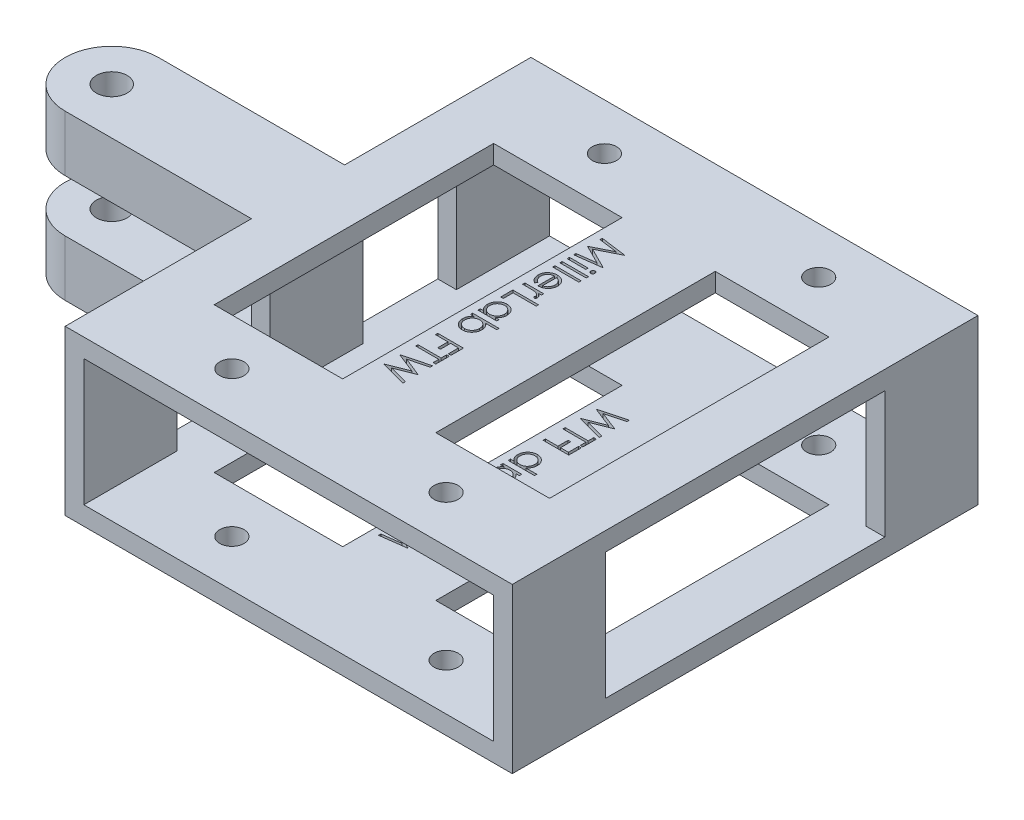
from build123d import *

# Parameters (mm, degrees)
SKETCH1_W             = 60.96
SKETCH1_H             = 22.352
SKETCH1_W_2           = 55.88
SKETCH1_H_2           = 17.272
BOSS_EXTRUDE1_DEPTH   = 12.7
SKETCH2_W             = 7.62
SKETCH2_H             = 2.54
SKETCH2_W_2           = 12.7
BOSS_EXTRUDE2_DEPTH   = 38.1
SKETCH4_W             = 60.96
SKETCH4_H             = 22.352
SKETCH4_W_2           = 55.88
SKETCH4_H_2           = 17.272
BOSS_EXTRUDE3_DEPTH   = 12.7
SKETCH6_W             = 12.7
SKETCH6_H             = 22.352
BOSS_EXTRUDE4_DEPTH   = 2.54
SKETCH7_W             = 12.7
SKETCH7_H             = 5.08
BOSS_EXTRUDE5_DEPTH   = 25.4
SKETCH8_W             = 6.35
SKETCH8_H             = 5.08
REVOLVE2_ANGLE        = 180
SKETCH10_R            = 2.0955
CUT_EXTRUDE4_DEPTH    = 20.812
SKETCH11_W            = 2.557692308
SKETCH11_H            = 0.314102564
SKETCH11_W_2          = 3.58974359
CUT_EXTRUDE7_DEPTH    = 2.54
SKETCH14_W            = 2.557692308
SKETCH14_H            = 0.314102564
SKETCH14_W_2          = 3.58974359
CUT_EXTRUDE8_DEPTH    = 2.54
M4X0_7_TAPPED_HOLE1_D = 3.3
SKETCH17_R            = 2.0955
BOSS_EXTRUDE6_DEPTH   = 2.54
SKETCH18_R            = 2.0955
BOSS_EXTRUDE7_DEPTH   = 2.54


with BuildPart() as part:
    # Sketch1 → Boss-Extrude1 (new body)
    with BuildSketch(Plane.XY):
        Rectangle(SKETCH1_W, SKETCH1_H)
        Rectangle(SKETCH1_W_2, SKETCH1_H_2, mode=Mode.SUBTRACT)
    extrude(amount=-BOSS_EXTRUDE1_DEPTH)

    # Sketch2 → Boss-Extrude2 (add)
    with BuildSketch(Plane(origin=(0, 0, -12.7), x_dir=(-1, 0, 0), z_dir=(0, 0, -1))):
        with Locations((-26.67, 9.906)):
            Rectangle(SKETCH2_W, SKETCH2_H)
        with Locations((-1.00660043, 9.906)):
            Rectangle(SKETCH2_W_2, SKETCH2_H)
        with Locations((26.67, 9.906)):
            Rectangle(SKETCH2_W, SKETCH2_H)
        with Locations((26.67, -9.906)):
            Rectangle(SKETCH2_W, SKETCH2_H)
        with Locations((-1.00660043, -9.906)):
            Rectangle(SKETCH2_W_2, SKETCH2_H)
        with Locations((-26.67, -9.906)):
            Rectangle(SKETCH2_W, SKETCH2_H)
    extrude(amount=BOSS_EXTRUDE2_DEPTH)

    # Sketch4 → Boss-Extrude3 (add)
    with BuildSketch(Plane(origin=(0, 0, -50.8), x_dir=(-1, 0, 0), z_dir=(0, 0, -1))):
        Rectangle(SKETCH4_W, SKETCH4_H)
        Rectangle(SKETCH4_W_2, SKETCH4_H_2, mode=Mode.SUBTRACT)
    extrude(amount=BOSS_EXTRUDE3_DEPTH)

    # Sketch6 → Boss-Extrude4 (add)
    with BuildSketch(Plane.ZY.offset(30.48)):
        with Locations((-31.75, 0)):
            Rectangle(SKETCH6_W, SKETCH6_H)
    extrude(amount=-BOSS_EXTRUDE4_DEPTH)

    # Sketch7 → Boss-Extrude5 (add)
    with BuildSketch(Plane.ZY.offset(30.48)):
        with Locations((-31.75, 6.096)):
            Rectangle(SKETCH7_W, SKETCH7_H)
        with Locations((-31.75, -6.096)):
            Rectangle(SKETCH7_W, SKETCH7_H)
    extrude(amount=BOSS_EXTRUDE5_DEPTH)

    # Sketch8 → Revolve2 (revolve)
    with BuildSketch(Plane.ZY.offset(55.88)):
        with Locations((-28.575, 6.096)):
            Rectangle(SKETCH8_W, SKETCH8_H)
        with Locations((-28.575, -6.096)):
            Rectangle(SKETCH8_W, SKETCH8_H)
    revolve(axis=Axis((-55.88, 8.636, -31.75), (0, -1, 0)), revolution_arc=REVOLVE2_ANGLE)

    # Sketch10 → Cut-Extrude4 (cut, through all)
    with BuildSketch(Plane(origin=(0, 8.636, 0), x_dir=(1, 0, 0), z_dir=(0, 1, 0))):
        with Locations((-55.88, 31.75)):
            Circle(SKETCH10_R)
    extrude(amount=-CUT_EXTRUDE4_DEPTH, mode=Mode.SUBTRACT)

    # Sketch11 → Cut-Extrude7 (cut)
    with BuildSketch(Plane(origin=(0, -11.176, 0), x_dir=(-1, 0, 0), z_dir=(0, -1, 0))):
        Polygon((4.247617225, 16.493589744), (0.747617225, 16.955629006), (0.747617225, 17.000500801), (3.619412097, 18.445512821), (0.747617225, 19.887019231), (0.747617225, 19.932592147), (4.247617225, 20.397435897), (4.247617225, 20.08193109), (1.729187738, 19.746794872), (4.247617225, 18.483373397), (4.247617225, 18.412560096), (1.723578763, 17.144230769), (4.247617225, 16.809795673), align=None)
        with BuildLine():
            add(Edge.make_bspline(
                [(0.61300184, 21.136418269), (0.613905993, 21.155909585), (0.615676497, 21.194077325), (0.630837974, 21.249270593), (0.656537659, 21.299527605), (0.69101734, 21.344105338), (0.731566784, 21.382357224), (0.778827752, 21.409137935), (0.829886391, 21.426350331), (0.86550148, 21.428428886), (0.883634853, 21.429487179)],
                knots=[0, 0, 0, 0, 5.84e-05, 0.000114358, 0.000170171, 0.000226684, 0.000282761, 0.000336156, 0.000388483, 0.00044276, 0.00044276, 0.00044276, 0.00044276], degree=3))
            add(Edge.make_bspline(
                [(0.883634853, 21.429487179), (0.901297506, 21.42840502), (0.936214481, 21.426265718), (0.986387953, 21.40915123), (1.032992237, 21.382128992), (1.073462947, 21.344129866), (1.107923567, 21.299521105), (1.133628306, 21.249272319), (1.148788443, 21.194076871), (1.150559132, 21.155909431), (1.151463379, 21.136418269)],
                knots=[0, 0, 0, 0, 5.2882e-05, 0.000104542, 0.000157332, 0.000213408, 0.000269922, 0.000325735, 0.000381693, 0.000440092, 0.000440092, 0.000440092, 0.000440092], degree=3))
            add(Edge.make_bspline(
                [(1.151463379, 21.136418269), (1.150593659, 21.117149994), (1.148900862, 21.079646814), (1.133330844, 21.025279972), (1.107914771, 20.975451482), (1.073688586, 20.93078681), (1.032743689, 20.893556616), (0.986416395, 20.866458291), (0.93620724, 20.849383329), (0.901295074, 20.8472387), (0.883634853, 20.846153846)],
                knots=[0, 0, 0, 0, 5.7701e-05, 0.000112308, 0.000168121, 0.000224634, 0.000280239, 0.000333029, 0.000384689, 0.000437571, 0.000437571, 0.000437571, 0.000437571], degree=3))
            add(Edge.make_bspline(
                [(0.883634853, 20.846153846), (0.865504004, 20.847214933), (0.829893871, 20.849298974), (0.778798838, 20.86647109), (0.731817336, 20.893330898), (0.690791837, 20.930811461), (0.656546402, 20.975444922), (0.631135421, 21.025281667), (0.615564081, 21.079646366), (0.613871467, 21.117149842), (0.61300184, 21.136418269)],
                knots=[0, 0, 0, 0, 5.4277e-05, 0.000106603, 0.000159999, 0.000215605, 0.000272118, 0.000327931, 0.000382538, 0.000440239, 0.000440239, 0.000440239, 0.000440239], degree=3))
        make_face()
        with Locations((2.968771071, 21.137820513)):
            Rectangle(SKETCH11_W, SKETCH11_H)
        with Locations((2.45274543, 22.125)):
            Rectangle(SKETCH11_W_2, SKETCH11_H)
        with Locations((2.45274543, 23.112179487)):
            Rectangle(SKETCH11_W_2, SKETCH11_H)
        with BuildLine():
            Line((3.439924917, 26.086338141), (3.586459372, 26.365384615))
            add(Edge.make_bspline(
                [(3.586459372, 26.365384615), (3.625893354, 26.343136354), (3.702616265, 26.299850049), (3.808030234, 26.225713126), (3.902297768, 26.147284659), (3.983909375, 26.062178381), (4.055982557, 25.972958905), (4.118149707, 25.877931674), (4.171532545, 25.777872338), (4.215274799, 25.671678794), (4.249663078, 25.559478251), (4.275059057, 25.440619641), (4.289786311, 25.314541759), (4.291573757, 25.228203797), (4.29248902, 25.183994391)],
                knots=[0, 0, 0, 0, 0.000135759, 0.000264133, 0.000386042, 0.00050306, 0.000617265, 0.000729664, 0.000843204, 0.000957002, 0.001073654, 0.001194802, 0.001321164, 0.001453767, 0.001453767, 0.001453767, 0.001453767], degree=3))
            add(Edge.make_bspline(
                [(4.29248902, 25.183994391), (4.291341844, 25.134852414), (4.289104038, 25.038990652), (4.269811574, 24.899450904), (4.238339213, 24.76807149), (4.194373678, 24.644859772), (4.136946332, 24.530117572), (4.06698693, 24.423616521), (3.984854375, 24.324797737), (3.889839071, 24.236770712), (3.788152887, 24.157537276), (3.682212278, 24.087573696), (3.572384128, 24.029353967), (3.459321889, 23.981271988), (3.343282485, 23.943344417), (3.223601343, 23.916392501), (3.100753036, 23.900999352), (3.017657427, 23.898629938), (2.975782289, 23.897435897)],
                knots=[0, 0, 0, 0, 0.000147371, 0.000287478, 0.000421649, 0.000552053, 0.000679042, 0.000805636, 0.000933558, 0.00106351, 0.001193382, 0.001319977, 0.001443869, 0.00156576, 0.001688149, 0.001809597, 0.001933259, 0.002058885, 0.002058885, 0.002058885, 0.002058885], degree=3))
            add(Edge.make_bspline(
                [(2.975782289, 23.897435897), (2.936487459, 23.898495039), (2.858610294, 23.900594117), (2.743344749, 23.913824904), (2.631316297, 23.937273197), (2.522431849, 23.969449521), (2.416873715, 24.011000768), (2.314577651, 24.061832987), (2.215652511, 24.122025365), (2.153249378, 24.168498038), (2.121815943, 24.191907051)],
                knots=[0, 0, 0, 0, 0.000117891, 0.000233644, 0.000347498, 0.000460856, 0.000573868, 0.000687374, 0.000803169, 0.000920699, 0.000920699, 0.000920699, 0.000920699], degree=3))
            add(Edge.make_bspline(
                [(2.121815943, 24.191907051), (2.083884284, 24.223560071), (2.009344387, 24.285761747), (1.912294563, 24.392058508), (1.829276736, 24.505608288), (1.761550628, 24.627553262), (1.709458542, 24.757688021), (1.672406131, 24.895341339), (1.649350429, 25.040893688), (1.646507336, 25.140671415), (1.645053122, 25.191706731)],
                knots=[0, 0, 0, 0, 0.000148071, 0.000290976, 0.000430515, 0.000569233, 0.000708282, 0.00084996, 0.000996123, 0.001149162, 0.001149162, 0.001149162, 0.001149162], degree=3))
            add(Edge.make_bspline(
                [(1.645053122, 25.191706731), (1.64640039, 25.244157352), (1.649043421, 25.347053514), (1.673765573, 25.497043025), (1.712494308, 25.639244931), (1.768920238, 25.772485713), (1.838864031, 25.898818414), (1.927269712, 26.015335502), (2.029596658, 26.125235447), (2.108372465, 26.189137332), (2.148458571, 26.221654647)],
                knots=[0, 0, 0, 0, 0.000157241, 0.00030847, 0.000454763, 0.000598385, 0.000741531, 0.000886803, 0.001036096, 0.001190777, 0.001190777, 0.001190777, 0.001190777], degree=3))
            add(Edge.make_bspline(
                [(2.148458571, 26.221654647), (2.178662153, 26.243781586), (2.238868271, 26.287888179), (2.337039428, 26.343135279), (2.439750023, 26.391092674), (2.54866032, 26.429425635), (2.6624799, 26.460465136), (2.782022445, 26.482921955), (2.907252356, 26.496091573), (2.992578911, 26.498680271), (3.036078763, 26.5)],
                knots=[0, 0, 0, 0, 0.000112234, 0.000223721, 0.000337279, 0.000451932, 0.000569628, 0.000690912, 0.000816421, 0.00094695, 0.00094695, 0.00094695, 0.00094695], degree=3))
            Line((3.036078763, 26.5), (3.036078763, 24.211538462))
            add(Edge.make_bspline(
                [(3.036078763, 24.211538462), (3.069779228, 24.213078068), (3.136049831, 24.216105642), (3.233020615, 24.230220785), (3.325393957, 24.252469559), (3.412476999, 24.283738621), (3.495407126, 24.321605467), (3.573569163, 24.367991184), (3.646607093, 24.423330737), (3.715174231, 24.485056437), (3.776234992, 24.553763532), (3.830886768, 24.626046279), (3.876692365, 24.702939844), (3.913872255, 24.783837928), (3.942978571, 24.868609713), (3.962846391, 24.957281908), (3.976153498, 25.049680025), (3.977633163, 25.112665759), (3.978386456, 25.144731571)],
                knots=[0, 0, 0, 0, 0.000101159, 0.000198924, 0.000293472, 0.000385722, 0.000476069, 0.000566611, 0.000657757, 0.000750573, 0.000842919, 0.000933083, 0.001022062, 0.001110842, 0.001199752, 0.001290403, 0.001383113, 0.001479259, 0.001479259, 0.001479259, 0.001479259], degree=3))
            add(Edge.make_bspline(
                [(3.978386456, 25.144731571), (3.977783296, 25.176084086), (3.97658651, 25.238293491), (3.96478247, 25.330914198), (3.946074092, 25.422195018), (3.919128337, 25.511229558), (3.887575222, 25.596720251), (3.850437409, 25.676326669), (3.808096098, 25.748996376), (3.759980502, 25.817180712), (3.700930029, 25.882958118), (3.627948805, 25.949242628), (3.540209077, 26.018748352), (3.4746109, 26.062960389), (3.439924917, 26.086338141)],
                knots=[0, 0, 0, 0, 9.4016e-05, 0.000186545, 0.000279636, 0.000373251, 0.000465322, 0.000552831, 0.000636406, 0.000717339, 0.000802755, 0.000900997, 0.001012795, 0.001138241, 0.001138241, 0.001138241, 0.001138241], degree=3))
        make_face()
        with BuildLine():
            add(Edge.make_bspline(
                [(2.721976199, 26.185897436), (2.680292506, 26.174447368), (2.600273356, 26.152466957), (2.489504895, 26.105655852), (2.390493119, 26.054207803), (2.304883383, 25.992274475), (2.228728754, 25.922787657), (2.163242181, 25.841416914), (2.102884461, 25.751691387), (2.052620849, 25.651823925), (2.011316259, 25.545752804), (1.980944618, 25.435658203), (1.963091257, 25.322462266), (1.96047371, 25.246222059), (1.959155687, 25.207832532)],
                knots=[0, 0, 0, 0, 0.000129543, 0.00024868, 0.000360034, 0.000463544, 0.000564759, 0.000668354, 0.000776083, 0.000888652, 0.001002969, 0.001117099, 0.00123064, 0.001345797, 0.001345797, 0.001345797, 0.001345797], degree=3))
            add(Edge.make_bspline(
                [(1.959155687, 25.207832532), (1.959760225, 25.176480698), (1.960955271, 25.114504713), (1.972528457, 25.023238257), (1.99112528, 24.935362925), (2.018469047, 24.851141019), (2.051741006, 24.770013865), (2.092638976, 24.692040085), (2.142085337, 24.618222044), (2.179857154, 24.572085873), (2.19893934, 24.548778045)],
                knots=[0, 0, 0, 0, 9.4016e-05, 0.000185849, 0.000275511, 0.000363095, 0.000451113, 0.0005383, 0.000626778, 0.000717114, 0.000717114, 0.000717114, 0.000717114], degree=3))
            add(Edge.make_bspline(
                [(2.19893934, 24.548778045), (2.214032069, 24.532082147), (2.244576075, 24.498293718), (2.297230043, 24.45319403), (2.354040592, 24.40969064), (2.417487555, 24.371031539), (2.485731038, 24.334291803), (2.559268997, 24.300812377), (2.638411838, 24.270371333), (2.693588551, 24.253282931), (2.721976199, 24.244491186)],
                knots=[0, 0, 0, 0, 6.7454e-05, 0.00013651, 0.000207604, 0.000281922, 0.000359087, 0.000440033, 0.000524147, 0.00061328, 0.00061328, 0.00061328, 0.00061328], degree=3))
            Line((2.721976199, 24.244491186), (2.721976199, 26.185897436))
        make_face(mode=Mode.SUBTRACT)
        with BuildLine():
            Line((1.689924917, 27.038461538), (1.689924917, 27.352564103))
            Line((1.689924917, 27.352564103), (2.066427321, 27.352564103))
            add(Edge.make_bspline(
                [(2.066427321, 27.352564103), (2.031355799, 27.375738024), (1.964281786, 27.420057969), (1.875691167, 27.494067787), (1.801504013, 27.569067361), (1.743135084, 27.647026042), (1.699022427, 27.727179508), (1.668025845, 27.808851864), (1.648803921, 27.892242831), (1.646305063, 27.948418293), (1.645053122, 27.9765625)],
                knots=[0, 0, 0, 0, 0.000126023, 0.000241017, 0.000345635, 0.000441829, 0.000532198, 0.000619182, 0.000703214, 0.000787585, 0.000787585, 0.000787585, 0.000787585], degree=3))
            add(Edge.make_bspline(
                [(1.645053122, 27.9765625), (1.646243649, 27.998388826), (1.648693235, 28.043297912), (1.665904059, 28.111280501), (1.693382082, 28.181323953), (1.719222305, 28.226466341), (1.732693347, 28.25)],
                knots=[0, 0, 0, 0, 6.5445e-05, 0.000134658, 0.00020926, 0.000290509, 0.000290509, 0.000290509, 0.000290509], degree=3))
            Line((1.732693347, 28.25), (2.004728603, 28.077524038))
            add(Edge.make_bspline(
                [(2.004728603, 28.077524038), (1.997988337, 28.062415017), (1.985194022, 28.033735203), (1.970052012, 27.991780637), (1.961136096, 27.9530993), (1.959785378, 27.928455741), (1.959155687, 27.916967147)],
                knots=[0, 0, 0, 0, 4.9621e-05, 9.4191e-05, 0.00013366, 0.000168129, 0.000168129, 0.000168129, 0.000168129], degree=3))
            add(Edge.make_bspline(
                [(1.959155687, 27.916967147), (1.960822567, 27.891753846), (1.96422252, 27.840326021), (1.991333186, 27.765074687), (2.033876004, 27.691399312), (2.082319697, 27.633451078), (2.1288541, 27.588424214), (2.169581964, 27.556042035), (2.215672768, 27.526978548), (2.265345001, 27.498786194), (2.319845293, 27.472593368), (2.379262554, 27.449186231), (2.443106141, 27.427296051), (2.487498075, 27.414968511), (2.510237417, 27.408653846)],
                knots=[0, 0, 0, 0, 7.549e-05, 0.000153978, 0.000237202, 0.000329846, 0.000379433, 0.000431335, 0.000485594, 0.00054273, 0.000602625, 0.000666812, 0.000734214, 0.000805, 0.000805, 0.000805, 0.000805], degree=3))
            add(Edge.make_bspline(
                [(2.510237417, 27.408653846), (2.530513468, 27.403913274), (2.575648591, 27.393360613), (2.651025991, 27.38337422), (2.740024618, 27.373109836), (2.842747862, 27.366100296), (2.959590594, 27.35947885), (3.090048753, 27.35582089), (3.234480907, 27.352680486), (3.335221767, 27.352604135), (3.388041904, 27.352564103)],
                knots=[0, 0, 0, 0, 6.2435e-05, 0.000138983, 0.000227868, 0.000331221, 0.000447778, 0.000578955, 0.000722713, 0.000881168, 0.000881168, 0.000881168, 0.000881168], degree=3))
            Line((3.388041904, 27.352564103), (4.247617225, 27.352564103))
            Line((4.247617225, 27.352564103), (4.247617225, 27.038461538))
            Line((4.247617225, 27.038461538), (1.689924917, 27.038461538))
        make_face()
        Polygon((0.747617225, 28.698717949), (0.747617225, 29.012820513), (3.888642866, 29.012820513), (3.888642866, 30.358974359), (4.247617225, 30.358974359), (4.247617225, 28.698717949), align=None)
        with BuildLine():
            Line((1.689924917, 33.455128205), (4.247617225, 33.455128205))
            Line((4.247617225, 33.455128205), (4.247617225, 33.141025641))
            Line((4.247617225, 33.141025641), (3.805209372, 33.141025641))
            add(Edge.make_bspline(
                [(3.805209372, 33.141025641), (3.845182992, 33.105551556), (3.923308021, 33.036220483), (4.026308805, 32.921515667), (4.109711173, 32.798417096), (4.178049309, 32.670013674), (4.229175191, 32.535047659), (4.265579222, 32.394224474), (4.288968191, 32.247409579), (4.291304881, 32.147157707), (4.29248902, 32.096354167)],
                knots=[0, 0, 0, 0, 0.000160263, 0.00031322, 0.000461017, 0.000605284, 0.000748646, 0.000892854, 0.001041096, 0.001193401, 0.001193401, 0.001193401, 0.001193401], degree=3))
            add(Edge.make_bspline(
                [(4.29248902, 32.096354167), (4.291262648, 32.051186213), (4.288844187, 31.962113008), (4.270081884, 31.831083931), (4.239951262, 31.704991681), (4.198050372, 31.583717109), (4.142469551, 31.468044963), (4.075928303, 31.356984867), (3.996687473, 31.251112175), (3.906099444, 31.152040636), (3.807704457, 31.060808635), (3.70275891, 30.980747363), (3.591716606, 30.913994283), (3.475983452, 30.858174202), (3.354668533, 30.815177858), (3.228191365, 30.785204223), (3.096701491, 30.766463777), (3.007161968, 30.764046316), (2.961759853, 30.762820513)],
                knots=[0, 0, 0, 0, 0.000135464, 0.00026714, 0.000396211, 0.000523931, 0.000651257, 0.000780517, 0.000911767, 0.001047265, 0.00118272, 0.001313831, 0.001442491, 0.001570752, 0.001698704, 0.001827775, 0.001960146, 0.00209631, 0.00209631, 0.00209631, 0.00209631], degree=3))
            add(Edge.make_bspline(
                [(2.961759853, 30.762820513), (2.91729615, 30.764073484), (2.829393806, 30.766550541), (2.700115108, 30.785003761), (2.575596848, 30.81603477), (2.456239904, 30.859582617), (2.341899854, 30.915424572), (2.232495829, 30.983352659), (2.127726432, 31.063371784), (2.030055205, 31.155624191), (1.939834591, 31.255558961), (1.861425545, 31.362467692), (1.793708696, 31.473690973), (1.74005522, 31.590953984), (1.696646116, 31.712521089), (1.666613147, 31.839474534), (1.648915826, 31.971286113), (1.646353062, 32.060776605), (1.645053122, 32.106169872)],
                knots=[0, 0, 0, 0, 0.000133363, 0.00026365, 0.000390846, 0.000517716, 0.000644083, 0.000771912, 0.000903449, 0.001038867, 0.001174416, 0.001306792, 0.001436052, 0.00156435, 0.001692963, 0.001822716, 0.001954992, 0.002091156, 0.002091156, 0.002091156, 0.002091156], degree=3))
            add(Edge.make_bspline(
                [(1.645053122, 32.106169872), (1.646492475, 32.158368742), (1.649314979, 32.260728263), (1.672755064, 32.410470251), (1.712476107, 32.552063751), (1.766134384, 32.687011914), (1.838930692, 32.813457215), (1.928190884, 32.93297371), (2.03760529, 33.043018675), (2.120599079, 33.107791523), (2.163182129, 33.141025641)],
                knots=[0, 0, 0, 0, 0.00015654, 0.000306968, 0.000453261, 0.000596998, 0.000741444, 0.000889661, 0.001043352, 0.001205306, 0.001205306, 0.001205306, 0.001205306], degree=3))
            Line((2.163182129, 33.141025641), (1.689924917, 33.141025641))
            Line((1.689924917, 33.141025641), (1.689924917, 33.455128205))
        make_face()
        with BuildLine():
            add(Edge.make_bspline(
                [(1.959155687, 32.110376603), (1.960790722, 32.064463253), (1.964018023, 31.973837603), (1.989171299, 31.840779311), (2.031131873, 31.713519594), (2.08818219, 31.592256343), (2.161279929, 31.48037106), (2.247402562, 31.378621623), (2.348003806, 31.290145364), (2.459483431, 31.214055996), (2.579655727, 31.152973248), (2.705236648, 31.109748979), (2.83405286, 31.081294508), (2.921414046, 31.078384015), (2.965265462, 31.076923077)],
                knots=[0, 0, 0, 0, 0.000137677, 0.000271753, 0.000404561, 0.000538791, 0.000672586, 0.000804376, 0.000937479, 0.001073216, 0.001208358, 0.001340511, 0.001470867, 0.001602247, 0.001602247, 0.001602247, 0.001602247], degree=3))
            add(Edge.make_bspline(
                [(2.965265462, 31.076923077), (3.008852816, 31.078795496), (3.095856677, 31.082532995), (3.224661832, 31.10912599), (3.34996086, 31.154325513), (3.471098844, 31.215325664), (3.58366775, 31.292310546), (3.686075908, 31.380702658), (3.773545688, 31.482941638), (3.846819648, 31.595827247), (3.905972419, 31.716446444), (3.947140618, 31.843277429), (3.973717727, 31.97395384), (3.976822295, 32.06280607), (3.978386456, 32.107572115)],
                knots=[0, 0, 0, 0, 0.000130727, 0.000260941, 0.000392666, 0.000529376, 0.000666667, 0.000800822, 0.000934057, 0.001068822, 0.001203658, 0.0013358, 0.001467941, 0.001602119, 0.001602119, 0.001602119, 0.001602119], degree=3))
            add(Edge.make_bspline(
                [(3.978386456, 32.107572115), (3.976707315, 32.153012426), (3.973367671, 32.243388697), (3.948356704, 32.376990324), (3.905467398, 32.506200286), (3.847828606, 32.630137167), (3.776038008, 32.74548194), (3.691990611, 32.848654567), (3.594916264, 32.936926688), (3.486990986, 33.010419689), (3.369427008, 33.068703229), (3.244387715, 33.111319409), (3.111619306, 33.136235958), (3.020759002, 33.139407004), (2.974380045, 33.141025641)],
                knots=[0, 0, 0, 0, 0.000136278, 0.000271043, 0.000406068, 0.000543769, 0.000680144, 0.000812646, 0.000941683, 0.001072365, 0.001203116, 0.001334151, 0.001467537, 0.001606614, 0.001606614, 0.001606614, 0.001606614], degree=3))
            add(Edge.make_bspline(
                [(2.974380045, 33.141025641), (2.939042215, 33.140065985), (2.869486182, 33.138177077), (2.767358664, 33.123746508), (2.669624938, 33.100791581), (2.576182249, 33.068445411), (2.487547234, 33.025954127), (2.403083473, 32.974706361), (2.323230262, 32.913800911), (2.249087191, 32.844218215), (2.181460729, 32.768053013), (2.121096488, 32.687458472), (2.071507715, 32.601479725), (2.030466444, 32.511562688), (1.997807294, 32.417551354), (1.9760196, 32.318680734), (1.961059279, 32.216001747), (1.959796898, 32.145955691), (1.959155687, 32.110376603)],
                knots=[0, 0, 0, 0, 0.000105983, 0.000208608, 0.000308773, 0.00040678, 0.000504626, 0.000603105, 0.000702667, 0.00080535, 0.000907651, 0.001007914, 0.001106881, 0.00120477, 0.001304102, 0.001404791, 0.00150811, 0.001614764, 0.001614764, 0.001614764, 0.001614764], degree=3))
        make_face(mode=Mode.SUBTRACT)
        with BuildLine():
            Line((4.247617225, 34.173076923), (0.657873635, 34.173076923))
            Line((0.657873635, 34.173076923), (0.657873635, 34.487179487))
            Line((0.657873635, 34.487179487), (2.154067545, 34.487179487))
            add(Edge.make_bspline(
                [(2.154067545, 34.487179487), (2.113309614, 34.522572906), (2.033789208, 34.591626926), (1.929941558, 34.707403377), (1.841889081, 34.828808946), (1.769302963, 34.956767202), (1.714029356, 35.091460135), (1.673606966, 35.232192244), (1.649220063, 35.379323285), (1.64645399, 35.479642459), (1.645053122, 35.530448718)],
                knots=[0, 0, 0, 0, 0.000161815, 0.000315708, 0.000465351, 0.000611017, 0.000755934, 0.000901068, 0.001049529, 0.001201867, 0.001201867, 0.001201867, 0.001201867], degree=3))
            add(Edge.make_bspline(
                [(1.645053122, 35.530448718), (1.646293351, 35.575614856), (1.648745493, 35.664916008), (1.667379988, 35.796198155), (1.69759779, 35.92251143), (1.73948997, 36.043787078), (1.795072947, 36.15945921), (1.861614255, 36.270518267), (1.940852584, 36.376395252), (2.031450895, 36.475450137), (2.129807517, 36.566744024), (2.234987833, 36.646656534), (2.345462923, 36.71415623), (2.460862986, 36.769987523), (2.581659337, 36.813158575), (2.707733535, 36.842900843), (2.838961554, 36.861794307), (2.928274357, 36.864174553), (2.973678924, 36.865384615)],
                knots=[0, 0, 0, 0, 0.000135464, 0.000267835, 0.000396906, 0.000524625, 0.000651952, 0.000781211, 0.000912462, 0.00104796, 0.001183414, 0.001314526, 0.001443549, 0.001571179, 0.00169847, 0.001827542, 0.001959218, 0.002095382, 0.002095382, 0.002095382, 0.002095382], degree=3))
            add(Edge.make_bspline(
                [(2.973678924, 36.865384615), (3.018378941, 36.864148175), (3.106520337, 36.861710109), (3.236226893, 36.843088801), (3.361065592, 36.812342536), (3.480713849, 36.768381353), (3.595733763, 36.713116414), (3.704814167, 36.644005138), (3.809853142, 36.564194139), (3.907476774, 36.47186299), (3.997710174, 36.371949438), (4.076116039, 36.265035195), (4.143833159, 36.153813273), (4.197488607, 36.036550161), (4.240889528, 35.914982119), (4.271007219, 35.787806733), (4.288580274, 35.655743505), (4.291175841, 35.566024616), (4.29248902, 35.520633013)],
                knots=[0, 0, 0, 0, 0.000134063, 0.000264351, 0.000392226, 0.000519096, 0.000646094, 0.000774294, 0.000905831, 0.001041249, 0.001176798, 0.001309174, 0.001438434, 0.001566731, 0.001695345, 0.001825098, 0.001958069, 0.002094233, 0.002094233, 0.002094233, 0.002094233], degree=3))
            add(Edge.make_bspline(
                [(4.29248902, 35.520633013), (4.291050003, 35.468666917), (4.288228342, 35.366770465), (4.264786867, 35.2177317), (4.225007417, 35.076599382), (4.171186605, 34.942175692), (4.099804072, 34.81501228), (4.008728769, 34.697085471), (3.90073864, 34.585360566), (3.817297747, 34.520536971), (3.774360013, 34.487179487)],
                knots=[0, 0, 0, 0, 0.00015584, 0.000305575, 0.000451192, 0.000594929, 0.00073903, 0.000887111, 0.001040812, 0.001203751, 0.001203751, 0.001203751, 0.001203751], degree=3))
            Line((3.774360013, 34.487179487), (4.247617225, 34.487179487))
            Line((4.247617225, 34.487179487), (4.247617225, 34.173076923))
        make_face()
        with BuildLine():
            add(Edge.make_bspline(
                [(3.978386456, 35.517828526), (3.976752835, 35.563742891), (3.973528329, 35.654370544), (3.948354582, 35.787414154), (3.906470933, 35.914729042), (3.849185477, 36.035669574), (3.777169922, 36.148358343), (3.689999787, 36.248975999), (3.590443882, 36.338717499), (3.477677539, 36.412939775), (3.358324379, 36.475318438), (3.232985963, 36.51839993), (3.104677305, 36.546974819), (3.017535305, 36.549840052), (2.973678924, 36.551282051)],
                knots=[0, 0, 0, 0, 0.000137677, 0.000271753, 0.000404561, 0.000538791, 0.000672205, 0.000804452, 0.00093703, 0.001072956, 0.001208416, 0.001339907, 0.001469577, 0.001600956, 0.001600956, 0.001600956, 0.001600956], degree=3))
            add(Edge.make_bspline(
                [(2.973678924, 36.551282051), (2.929863382, 36.549394307), (2.842407221, 36.545626356), (2.712757554, 36.519251573), (2.587169929, 36.473193783), (2.465991941, 36.41207576), (2.35298414, 36.336207775), (2.251494013, 36.247201811), (2.163934029, 36.145320005), (2.090943958, 36.032496586), (2.031384405, 35.912316395), (1.990539379, 35.785825762), (1.963801192, 35.655667639), (1.960712063, 35.567272146), (1.959155687, 35.522736378)],
                knots=[0, 0, 0, 0, 0.000131426, 0.000262328, 0.000394949, 0.000531659, 0.000668557, 0.000802185, 0.00093542, 0.001070185, 0.001204391, 0.001336533, 0.001467986, 0.001601464, 0.001601464, 0.001601464, 0.001601464], degree=3))
            add(Edge.make_bspline(
                [(1.959155687, 35.522736378), (1.960711193, 35.477268884), (1.963798558, 35.387025134), (1.990586247, 35.253856717), (2.031634379, 35.123794181), (2.090563741, 34.999503794), (2.162682499, 34.883660225), (2.247396577, 34.780010078), (2.344129466, 34.690946685), (2.452094211, 34.616968834), (2.569386558, 34.558626331), (2.694703944, 34.517095389), (2.827075262, 34.491955214), (2.917712427, 34.488790766), (2.963863219, 34.487179487)],
                knots=[0, 0, 0, 0, 0.000136278, 0.000270483, 0.00040596, 0.000544592, 0.000681933, 0.000814436, 0.000944937, 0.00107504, 0.001205791, 0.001336603, 0.001469989, 0.001608366, 0.001608366, 0.001608366, 0.001608366], degree=3))
            add(Edge.make_bspline(
                [(2.963863219, 34.487179487), (2.999201166, 34.488138945), (3.068757428, 34.490027462), (3.170883282, 34.504460866), (3.268623099, 34.527405416), (3.362043621, 34.55978935), (3.450580712, 34.602054128), (3.534578995, 34.653698403), (3.614093868, 34.7143991), (3.688644876, 34.783301302), (3.756330608, 34.859517836), (3.815980934, 34.940578164), (3.866463383, 35.02626161), (3.906862079, 35.116512418), (3.939774011, 35.210634318), (3.961511743, 35.309529759), (3.976485695, 35.412201975), (3.977746198, 35.482248963), (3.978386456, 35.517828526)],
                knots=[0, 0, 0, 0, 0.000105983, 0.000208608, 0.000308773, 0.00040678, 0.000504626, 0.000602507, 0.000702069, 0.000804274, 0.000906575, 0.001007403, 0.001105765, 0.001204292, 0.001303624, 0.001404312, 0.001507632, 0.001614286, 0.001614286, 0.001614286, 0.001614286], degree=3))
        make_face(mode=Mode.SUBTRACT)
        Polygon((0.747617225, 38.929487179), (0.747617225, 40.634615385), (1.106591584, 40.634615385), (1.106591584, 39.243589744), (2.183514661, 39.243589744), (2.183514661, 40.634615385), (2.54248902, 40.634615385), (2.54248902, 39.243589744), (4.247617225, 39.243589744), (4.247617225, 38.929487179), align=None)
        Polygon((1.106591584, 40.858974359), (0.747617225, 40.858974359), (0.747617225, 42.698717949), (1.106591584, 42.698717949), (1.106591584, 41.935897436), (4.247617225, 41.935897436), (4.247617225, 41.621794872), (1.106591584, 41.621794872), align=None)
        Polygon((0.747617225, 43.102564103), (0.747617225, 43.427183494), (3.314424116, 44.112179487), (0.747617225, 45.130909455), (0.747617225, 45.176482372), (3.296896071, 46.176282051), (0.747617225, 46.864783654), (0.747617225, 47.185897436), (4.247617225, 46.2421875), (4.247617225, 46.197315705), (1.570734212, 45.144230769), (4.247617225, 44.078525641), (4.247617225, 44.033653846), align=None)
    extrude(amount=-CUT_EXTRUDE7_DEPTH, mode=Mode.SUBTRACT)

    # Sketch14 → Cut-Extrude8 (cut)
    with BuildSketch(Plane(origin=(0, 11.176, 0), x_dir=(1, 0, 0), z_dir=(0, 1, 0))):
        Polygon((-4.247617225, 47.006410256), (-0.747617225, 46.544370994), (-0.747617225, 46.499499199), (-3.619412097, 45.054487179), (-0.747617225, 43.612980769), (-0.747617225, 43.567407853), (-4.247617225, 43.102564103), (-4.247617225, 43.41806891), (-1.729187738, 43.753205128), (-4.247617225, 45.016626603), (-4.247617225, 45.087439904), (-1.723578763, 46.355769231), (-4.247617225, 46.690204327), align=None)
        with BuildLine():
            add(Edge.make_bspline(
                [(-0.61300184, 42.363581731), (-0.613909915, 42.344093669), (-0.615688099, 42.305932302), (-0.630793868, 42.250692809), (-0.656789642, 42.200444012), (-0.690532789, 42.155209421), (-0.731847908, 42.117712024), (-0.778791015, 42.090824395), (-0.829895895, 42.073659415), (-0.865504686, 42.071574402), (-0.883634853, 42.070512821)],
                knots=[0, 0, 0, 0, 5.84e-05, 0.000114358, 0.000170171, 0.000227242, 0.000282848, 0.000336244, 0.00038857, 0.000442847, 0.000442847, 0.000442847, 0.000442847], degree=3))
            add(Edge.make_bspline(
                [(-0.883634853, 42.070512821), (-0.901294417, 42.07159815), (-0.936205286, 42.073743719), (-0.986424072, 42.090811706), (-1.032713506, 42.117937446), (-1.073947851, 42.155184463), (-1.107671505, 42.200450604), (-1.133672428, 42.250691065), (-1.148776837, 42.305932761), (-1.150555209, 42.344093824), (-1.151463379, 42.363581731)],
                knots=[0, 0, 0, 0, 5.2882e-05, 0.000104542, 0.000157332, 0.000212937, 0.000270009, 0.000325822, 0.00038178, 0.00044018, 0.00044018, 0.00044018, 0.00044018], degree=3))
            add(Edge.make_bspline(
                [(-1.151463379, 42.363581731), (-1.150584376, 42.382845814), (-1.148873512, 42.420340835), (-1.133491717, 42.474564637), (-1.107728046, 42.524004912), (-1.073481161, 42.568499748), (-1.032987688, 42.606485241), (-0.986389106, 42.633510894), (-0.936214188, 42.650624516), (-0.901297408, 42.652763935), (-0.883634853, 42.653846154)],
                knots=[0, 0, 0, 0, 5.7701e-05, 0.000112308, 0.000167496, 0.000224009, 0.000280086, 0.000332875, 0.000384535, 0.000437418, 0.000437418, 0.000437418, 0.000437418], degree=3))
            add(Edge.make_bspline(
                [(-0.883634853, 42.653846154), (-0.865501582, 42.652787799), (-0.829886694, 42.650709123), (-0.778826578, 42.633497611), (-0.731571387, 42.606713443), (-0.690999141, 42.568475205), (-0.656733225, 42.524011338), (-0.63097453, 42.474562964), (-0.615591435, 42.420341279), (-0.613880751, 42.382845965), (-0.61300184, 42.363581731)],
                knots=[0, 0, 0, 0, 5.4277e-05, 0.000106603, 0.000159999, 0.000216076, 0.000272589, 0.000327778, 0.000382384, 0.000440085, 0.000440085, 0.000440085, 0.000440085], degree=3))
        make_face()
        with Locations((-2.968771071, 42.362179487)):
            Rectangle(SKETCH14_W, SKETCH14_H)
        with Locations((-2.45274543, 41.375)):
            Rectangle(SKETCH14_W_2, SKETCH14_H)
        with Locations((-2.45274543, 40.387820513)):
            Rectangle(SKETCH14_W_2, SKETCH14_H)
        with BuildLine():
            Line((-3.439924917, 37.413661859), (-3.586459372, 37.134615385))
            add(Edge.make_bspline(
                [(-3.586459372, 37.134615385), (-3.625899477, 37.156855179), (-3.702634303, 37.200125011), (-3.8081106, 37.2744817), (-3.90267171, 37.352522657), (-3.984853776, 37.436939478), (-4.056106552, 37.526692447), (-4.118036295, 37.62191341), (-4.171391588, 37.722284179), (-4.216104823, 37.828158572), (-4.250525172, 37.940451309), (-4.274826334, 38.059474745), (-4.289850461, 38.185445702), (-4.291595481, 38.271791957), (-4.29248902, 38.316005609)],
                knots=[0, 0, 0, 0, 0.000135759, 0.000264133, 0.000386579, 0.000503094, 0.000616862, 0.000729847, 0.000843387, 0.000957455, 0.001074107, 0.001195111, 0.001321472, 0.001454075, 0.001454075, 0.001454075, 0.001454075], degree=3))
            add(Edge.make_bspline(
                [(-4.29248902, 38.316005609), (-4.291341844, 38.365147586), (-4.289104038, 38.461009348), (-4.269811574, 38.600549098), (-4.238339211, 38.731928505), (-4.194373685, 38.855140247), (-4.136946305, 38.969882359), (-4.066987033, 39.076383736), (-3.984853981, 39.175201284), (-3.889840565, 39.263233003), (-3.788147378, 39.342449023), (-3.682232083, 39.412475555), (-3.572040816, 39.470610947), (-3.459287259, 39.519500084), (-3.342933753, 39.556541619), (-3.223617995, 39.58365609), (-3.100748764, 39.598988182), (-3.017655996, 39.601365885), (-2.975782289, 39.602564103)],
                knots=[0, 0, 0, 0, 0.000147371, 0.000287478, 0.000421649, 0.000552053, 0.000679042, 0.000805636, 0.000933558, 0.00106351, 0.001193382, 0.001319977, 0.001443869, 0.00156668, 0.001688186, 0.001809634, 0.001933296, 0.002058922, 0.002058922, 0.002058922, 0.002058922], degree=3))
            add(Edge.make_bspline(
                [(-2.975782289, 39.602564103), (-2.936487459, 39.601504961), (-2.858610294, 39.599405883), (-2.743344749, 39.586175096), (-2.631316297, 39.562726803), (-2.522431849, 39.530550479), (-2.416873715, 39.488999232), (-2.314577651, 39.438167013), (-2.215652511, 39.377974635), (-2.153249378, 39.331501962), (-2.121815943, 39.308092949)],
                knots=[0, 0, 0, 0, 0.000117891, 0.000233644, 0.000347498, 0.000460856, 0.000573868, 0.000687374, 0.000803169, 0.000920699, 0.000920699, 0.000920699, 0.000920699], degree=3))
            add(Edge.make_bspline(
                [(-2.121815943, 39.308092949), (-2.083947073, 39.276385266), (-2.009408922, 39.213974319), (-1.911470597, 39.108417964), (-1.829426821, 38.994117768), (-1.761419685, 38.872506142), (-1.709746038, 38.742169667), (-1.671238456, 38.604860376), (-1.649660445, 38.45901479), (-1.646612611, 38.359309569), (-1.645053122, 38.308293269)],
                knots=[0, 0, 0, 0, 0.000148071, 0.000291452, 0.00043058, 0.000569298, 0.000708346, 0.00085021, 0.000996268, 0.001149307, 0.001149307, 0.001149307, 0.001149307], degree=3))
            add(Edge.make_bspline(
                [(-1.645053122, 38.308293269), (-1.646407171, 38.255845664), (-1.649063507, 38.152955418), (-1.67368984, 38.002923297), (-1.712742395, 37.86096258), (-1.767896185, 37.727130076), (-1.839055737, 37.601412215), (-1.927197578, 37.484626166), (-2.029615666, 37.374774653), (-2.108378875, 37.310866074), (-2.148458571, 37.278345353)],
                knots=[0, 0, 0, 0, 0.000157241, 0.00030847, 0.000454763, 0.000598116, 0.000741606, 0.000886879, 0.001036172, 0.001190853, 0.001190853, 0.001190853, 0.001190853], degree=3))
            add(Edge.make_bspline(
                [(-2.148458571, 37.278345353), (-2.178662153, 37.256218414), (-2.238868271, 37.212111821), (-2.337039428, 37.156864721), (-2.439750023, 37.108907326), (-2.54866032, 37.070574365), (-2.6624799, 37.039534864), (-2.782022445, 37.017078045), (-2.907252356, 37.003908427), (-2.992578911, 37.001319729), (-3.036078763, 37)],
                knots=[0, 0, 0, 0, 0.000112234, 0.000223721, 0.000337279, 0.000451932, 0.000569628, 0.000690912, 0.000816421, 0.00094695, 0.00094695, 0.00094695, 0.00094695], degree=3))
            Line((-3.036078763, 37), (-3.036078763, 39.288461538))
            add(Edge.make_bspline(
                [(-3.036078763, 39.288461538), (-3.069778546, 39.28692047), (-3.136047809, 39.283890021), (-3.233028281, 39.269795659), (-3.325366516, 39.247471581), (-3.412669084, 39.216440465), (-3.495222628, 39.177530646), (-3.573596098, 39.131365253), (-3.646599245, 39.075952143), (-3.715178096, 39.014247549), (-3.776227539, 38.945531046), (-3.830911981, 38.87326444), (-3.876491619, 38.796499215), (-3.914045734, 38.716009233), (-3.942949897, 38.631377067), (-3.962854286, 38.542721732), (-3.97615142, 38.450319017), (-3.977632462, 38.387333918), (-3.978386456, 38.355268429)],
                knots=[0, 0, 0, 0, 0.000101159, 0.000198924, 0.000293472, 0.000385722, 0.000476365, 0.000566907, 0.000658053, 0.000750869, 0.000843215, 0.000933379, 0.001022358, 0.001110502, 0.001199412, 0.001290063, 0.001382773, 0.001478918, 0.001478918, 0.001478918, 0.001478918], degree=3))
            add(Edge.make_bspline(
                [(-3.978386456, 38.355268429), (-3.977782628, 38.323916483), (-3.976584517, 38.261708208), (-3.964761356, 38.168851684), (-3.945956756, 38.077447556), (-3.920110646, 37.988152333), (-3.888271414, 37.902907522), (-3.85010641, 37.82373631), (-3.808371388, 37.750371978), (-3.759887354, 37.682199216), (-3.701156764, 37.616074225), (-3.627026659, 37.55130437), (-3.540253738, 37.48091689), (-3.474678932, 37.436959076), (-3.439924917, 37.413661859)],
                knots=[0, 0, 0, 0, 9.4016e-05, 0.000186545, 0.000280323, 0.00037374, 0.000465156, 0.000552964, 0.000637145, 0.000718078, 0.000803495, 0.000901782, 0.001013031, 0.001138477, 0.001138477, 0.001138477, 0.001138477], degree=3))
        make_face()
        with BuildLine():
            add(Edge.make_bspline(
                [(-2.721976199, 37.314102564), (-2.680303257, 37.325579583), (-2.600096257, 37.347669149), (-2.489290992, 37.394122905), (-2.39024297, 37.445249949), (-2.304587618, 37.506960879), (-2.229043995, 37.577484459), (-2.162359158, 37.658082917), (-2.102988036, 37.748566546), (-2.052822359, 37.848312109), (-2.010136144, 37.953957648), (-1.981510053, 38.064562836), (-1.961900767, 38.177420887), (-1.960074624, 38.253755138), (-1.959155687, 38.292167468)],
                knots=[0, 0, 0, 0, 0.000129543, 0.000249328, 0.000359734, 0.000463244, 0.000564935, 0.000668978, 0.000776321, 0.00088889, 0.001003462, 0.001117409, 0.00123106, 0.001346181, 0.001346181, 0.001346181, 0.001346181], degree=3))
            add(Edge.make_bspline(
                [(-1.959155687, 38.292167468), (-1.95976994, 38.323516039), (-1.960984189, 38.385485572), (-1.972417018, 38.47679918), (-1.991561098, 38.56465123), (-2.017056038, 38.649525441), (-2.052182899, 38.729944486), (-2.092535255, 38.808001145), (-2.142112066, 38.881767331), (-2.179866125, 38.927910561), (-2.19893934, 38.951221955)],
                knots=[0, 0, 0, 0, 9.4016e-05, 0.000185849, 0.000275511, 0.000363554, 0.000451197, 0.000538384, 0.000626862, 0.000717198, 0.000717198, 0.000717198, 0.000717198], degree=3))
            add(Edge.make_bspline(
                [(-2.19893934, 38.951221955), (-2.214033656, 38.967915237), (-2.244580872, 39.001698371), (-2.297210079, 39.046838893), (-2.353961641, 39.090059365), (-2.417006765, 39.129393018), (-2.485627544, 39.165470605), (-2.55924518, 39.199230582), (-2.63841831, 39.229616994), (-2.693590749, 39.246713104), (-2.721976199, 39.255508814)],
                knots=[0, 0, 0, 0, 6.7454e-05, 0.00013651, 0.000207604, 0.000281328, 0.000359112, 0.000440057, 0.000524171, 0.000613305, 0.000613305, 0.000613305, 0.000613305], degree=3))
            Line((-2.721976199, 39.255508814), (-2.721976199, 37.314102564))
        make_face(mode=Mode.SUBTRACT)
        with BuildLine():
            Line((-1.689924917, 36.461538462), (-1.689924917, 36.147435897))
            Line((-1.689924917, 36.147435897), (-2.066427321, 36.147435897))
            add(Edge.make_bspline(
                [(-2.066427321, 36.147435897), (-2.031367825, 36.124249925), (-1.964316811, 36.079906932), (-1.875695098, 36.006157856), (-1.801991498, 35.930639314), (-1.743925697, 35.852412136), (-1.700083378, 35.772130274), (-1.667700485, 35.691128693), (-1.648877115, 35.607729419), (-1.646329494, 35.551572444), (-1.645053122, 35.5234375)],
                knots=[0, 0, 0, 0, 0.000126023, 0.000241017, 0.000345147, 0.000441905, 0.000532273, 0.000618856, 0.000702888, 0.000787259, 0.000787259, 0.000787259, 0.000787259], degree=3))
            add(Edge.make_bspline(
                [(-1.645053122, 35.5234375), (-1.646217015, 35.501604102), (-1.648599678, 35.456907867), (-1.666178077, 35.389041752), (-1.693178049, 35.318830539), (-1.719189565, 35.273521841), (-1.732693347, 35.25)],
                knots=[0, 0, 0, 0, 6.5445e-05, 0.000133976, 0.000209232, 0.00029048, 0.00029048, 0.00029048, 0.00029048], degree=3))
            Line((-1.732693347, 35.25), (-2.004728603, 35.422475962))
            add(Edge.make_bspline(
                [(-2.004728603, 35.422475962), (-1.997988337, 35.437584983), (-1.985194022, 35.466264797), (-1.970052012, 35.508219363), (-1.961136096, 35.5469007), (-1.959785378, 35.571544259), (-1.959155687, 35.583032853)],
                knots=[0, 0, 0, 0, 4.9621e-05, 9.4191e-05, 0.00013366, 0.000168129, 0.000168129, 0.000168129, 0.000168129], degree=3))
            add(Edge.make_bspline(
                [(-1.959155687, 35.583032853), (-1.960773951, 35.608491872), (-1.964045259, 35.659957068), (-1.99159553, 35.735407317), (-2.034235875, 35.808953185), (-2.083208733, 35.866618145), (-2.129528595, 35.911609327), (-2.170198646, 35.943733221), (-2.215771117, 35.973220615), (-2.265502594, 36.001389483), (-2.320231917, 36.027056172), (-2.379415282, 36.051010727), (-2.443120367, 36.072669622), (-2.487502894, 36.085019862), (-2.510237417, 36.091346154)],
                knots=[0, 0, 0, 0, 7.6187e-05, 0.000154012, 0.000238193, 0.000330296, 0.000379883, 0.000431785, 0.000485456, 0.000542593, 0.000603121, 0.000666657, 0.000734059, 0.000804845, 0.000804845, 0.000804845, 0.000804845], degree=3))
            add(Edge.make_bspline(
                [(-2.510237417, 36.091346154), (-2.530514591, 36.096078547), (-2.575426989, 36.106560439), (-2.650775514, 36.116751977), (-2.739799173, 36.126821495), (-2.842745766, 36.133918113), (-2.95935821, 36.140496155), (-3.089814155, 36.144206237), (-3.234247507, 36.147309378), (-3.33522186, 36.147392445), (-3.388041904, 36.147435897)],
                knots=[0, 0, 0, 0, 6.2435e-05, 0.000138289, 0.000227871, 0.000331224, 0.000447781, 0.000578258, 0.000722716, 0.000881171, 0.000881171, 0.000881171, 0.000881171], degree=3))
            Line((-3.388041904, 36.147435897), (-4.247617225, 36.147435897))
            Line((-4.247617225, 36.147435897), (-4.247617225, 36.461538462))
            Line((-4.247617225, 36.461538462), (-1.689924917, 36.461538462))
        make_face()
        Polygon((-0.747617225, 34.801282051), (-0.747617225, 34.487179487), (-3.888642866, 34.487179487), (-3.888642866, 33.141025641), (-4.247617225, 33.141025641), (-4.247617225, 34.801282051), align=None)
        with BuildLine():
            Line((-1.689924917, 30.044871795), (-4.247617225, 30.044871795))
            Line((-4.247617225, 30.044871795), (-4.247617225, 30.358974359))
            Line((-4.247617225, 30.358974359), (-3.805209372, 30.358974359))
            add(Edge.make_bspline(
                [(-3.805209372, 30.358974359), (-3.845259773, 30.394385743), (-3.923418635, 30.463491505), (-4.025222398, 30.578891491), (-4.110063552, 30.700706608), (-4.177950372, 30.829348781), (-4.229332751, 30.964433114), (-4.265466329, 31.105574382), (-4.288988302, 31.252584478), (-4.291311645, 31.352840294), (-4.29248902, 31.403645833)],
                knots=[0, 0, 0, 0, 0.000160263, 0.000312755, 0.000460372, 0.00060464, 0.000748002, 0.000892888, 0.00104113, 0.001193435, 0.001193435, 0.001193435, 0.001193435], degree=3))
            add(Edge.make_bspline(
                [(-4.29248902, 31.403645833), (-4.291262851, 31.44881391), (-4.288844792, 31.537887357), (-4.270079562, 31.668914669), (-4.239959746, 31.795013436), (-4.198019086, 31.916264022), (-4.142673305, 32.031844855), (-4.075697266, 32.142407204), (-3.996720685, 32.2482091), (-3.906082049, 32.347238413), (-3.807739724, 32.438545893), (-3.702543284, 32.518430717), (-3.591937601, 32.586135705), (-3.475953761, 32.64177708), (-3.354676548, 32.684835294), (-3.228189161, 32.71479216), (-3.096702067, 32.733537168), (-3.007162162, 32.735954002), (-2.961759853, 32.737179487)],
                knots=[0, 0, 0, 0, 0.000135464, 0.00026714, 0.000396211, 0.000523931, 0.000651257, 0.000779917, 0.000911167, 0.001046665, 0.001182119, 0.001313231, 0.001442255, 0.001570516, 0.001698468, 0.001827539, 0.00195991, 0.002096074, 0.002096074, 0.002096074, 0.002096074], degree=3))
            add(Edge.make_bspline(
                [(-2.961759853, 32.737179487), (-2.91729596, 32.735926821), (-2.829393242, 32.733450368), (-2.700117283, 32.714992737), (-2.575588911, 32.683978011), (-2.456269426, 32.640369842), (-2.341678288, 32.584698879), (-2.232712061, 32.515829518), (-2.127703868, 32.435973481), (-2.030021135, 32.343690154), (-1.940117862, 32.243772017), (-1.860949352, 32.13737817), (-1.794145033, 32.025835238), (-1.739839616, 31.908919561), (-1.696685227, 31.787459007), (-1.666602462, 31.660530904), (-1.648918611, 31.528712469), (-1.646353999, 31.439222918), (-1.645053122, 31.393830128)],
                knots=[0, 0, 0, 0, 0.000133363, 0.00026365, 0.000390846, 0.000517716, 0.000644083, 0.000772283, 0.00090382, 0.001039238, 0.001174786, 0.001306599, 0.00143646, 0.001564122, 0.001692735, 0.001822488, 0.001954765, 0.002090929, 0.002090929, 0.002090929, 0.002090929], degree=3))
            add(Edge.make_bspline(
                [(-1.645053122, 31.393830128), (-1.646483873, 31.341628237), (-1.649289509, 31.239262793), (-1.672886327, 31.089340406), (-1.712261425, 30.947382247), (-1.766377204, 30.812570048), (-1.837756366, 30.685426779), (-1.928610972, 30.567517235), (-2.03686545, 30.456467706), (-2.120257916, 30.392103992), (-2.163182129, 30.358974359)],
                knots=[0, 0, 0, 0, 0.00015654, 0.000306968, 0.000453936, 0.000597673, 0.000741774, 0.000889855, 0.001043054, 0.001205551, 0.001205551, 0.001205551, 0.001205551], degree=3))
            Line((-2.163182129, 30.358974359), (-1.689924917, 30.358974359))
            Line((-1.689924917, 30.358974359), (-1.689924917, 30.044871795))
        make_face()
        with BuildLine():
            add(Edge.make_bspline(
                [(-1.959155687, 31.389623397), (-1.960789307, 31.435537763), (-1.964013813, 31.526165417), (-1.989187562, 31.65920902), (-2.031071201, 31.786523936), (-2.088356696, 31.907464361), (-2.160372106, 32.020153525), (-2.247542779, 32.120769722), (-2.347096658, 32.210516719), (-2.459870741, 32.284717988), (-2.57939129, 32.34727704), (-2.705279266, 32.390177018), (-2.834042169, 32.418724055), (-2.921410473, 32.421622189), (-2.965265462, 32.423076923)],
                knots=[0, 0, 0, 0, 0.000137677, 0.000271753, 0.000404561, 0.000538791, 0.000672205, 0.000804452, 0.00093703, 0.001072956, 0.001208416, 0.001340569, 0.001470925, 0.001602305, 0.001602305, 0.001602305, 0.001602305], degree=3))
            add(Edge.make_bspline(
                [(-2.965265462, 32.423076923), (-3.008849733, 32.421194839), (-3.095847439, 32.417438047), (-3.224992914, 32.390929497), (-3.350374099, 32.344999167), (-3.47155027, 32.283868031), (-3.584555835, 32.20800237), (-3.686056479, 32.119000215), (-3.773576743, 32.017100978), (-3.846831232, 31.904167382), (-3.905797612, 31.783732206), (-3.947377364, 31.657020565), (-3.973632739, 31.52625882), (-3.976796553, 31.437188254), (-3.978386456, 31.392427885)],
                knots=[0, 0, 0, 0, 0.000130727, 0.000260941, 0.000393563, 0.000530272, 0.000667171, 0.000800798, 0.000934034, 0.001068799, 0.001203635, 0.001335112, 0.00146794, 0.001602119, 0.001602119, 0.001602119, 0.001602119], degree=3))
            add(Edge.make_bspline(
                [(-3.978386456, 31.392427885), (-3.976751352, 31.346975982), (-3.973507563, 31.256806567), (-3.947912811, 31.123449827), (-3.90654994, 30.993834893), (-3.848444529, 30.86988983), (-3.776762102, 30.754511379), (-3.6924732, 30.651089271), (-3.595267106, 30.56277847), (-3.487577774, 30.488746216), (-3.370072848, 30.430264447), (-3.244433052, 30.389016498), (-3.111645731, 30.363682552), (-3.020767932, 30.360565457), (-2.974380045, 30.358974359)],
                knots=[0, 0, 0, 0, 0.000136278, 0.000270353, 0.00040583, 0.00054353, 0.000679905, 0.000812408, 0.000942435, 0.001072538, 0.001203289, 0.001334766, 0.001468152, 0.001607229, 0.001607229, 0.001607229, 0.001607229], degree=3))
            add(Edge.make_bspline(
                [(-2.974380045, 30.358974359), (-2.939042229, 30.359934031), (-2.869486222, 30.361822968), (-2.76735851, 30.376253321), (-2.669625497, 30.39920904), (-2.576180212, 30.431552323), (-2.487554849, 30.474054343), (-2.40305471, 30.525261648), (-2.323466901, 30.586224576), (-2.248892212, 30.65508787), (-2.181212869, 30.7313149), (-2.121560863, 30.812372468), (-2.071078852, 30.898056633), (-2.030680038, 30.988307249), (-1.997768138, 31.0824292), (-1.976030397, 31.181324628), (-1.961056448, 31.283996847), (-1.959795945, 31.354043835), (-1.959155687, 31.389623397)],
                knots=[0, 0, 0, 0, 0.000105983, 0.000208608, 0.000308773, 0.00040678, 0.000504626, 0.000603105, 0.000702667, 0.000804872, 0.000907174, 0.001008001, 0.001106363, 0.00120489, 0.001304222, 0.001404911, 0.00150823, 0.001614884, 0.001614884, 0.001614884, 0.001614884], degree=3))
        make_face(mode=Mode.SUBTRACT)
        with BuildLine():
            Line((-4.247617225, 29.326923077), (-0.657873635, 29.326923077))
            Line((-0.657873635, 29.326923077), (-0.657873635, 29.012820513))
            Line((-0.657873635, 29.012820513), (-2.154067545, 29.012820513))
            add(Edge.make_bspline(
                [(-2.154067545, 29.012820513), (-2.113226066, 28.97773869), (-2.033297524, 28.909082046), (-1.930476589, 28.792634278), (-1.841379703, 28.671756984), (-1.769746895, 28.543473628), (-1.713675671, 28.408909404), (-1.67385311, 28.26820787), (-1.649096149, 28.120933645), (-1.646416448, 28.020598035), (-1.645053122, 27.969551282)],
                knots=[0, 0, 0, 0, 0.000161345, 0.000315759, 0.000464834, 0.000611112, 0.000755381, 0.000901189, 0.001048958, 0.001201997, 0.001201997, 0.001201997, 0.001201997], degree=3))
            add(Edge.make_bspline(
                [(-1.645053122, 27.969551282), (-1.646290551, 27.924384087), (-1.648737159, 27.835080845), (-1.667412102, 27.703813974), (-1.697430007, 27.57765941), (-1.739833069, 27.456589795), (-1.794849545, 27.34067047), (-1.861645782, 27.229496236), (-1.940843149, 27.123599312), (-2.031455882, 27.024556698), (-2.129797318, 26.933234514), (-2.235022251, 26.853419271), (-2.345251613, 26.785620058), (-2.461210365, 26.731079411), (-2.581473606, 26.686576386), (-2.707763277, 26.657176694), (-2.838953758, 26.63818537), (-2.92827173, 26.635818597), (-2.973678924, 26.634615385)],
                knots=[0, 0, 0, 0, 0.000135464, 0.000267835, 0.000396906, 0.000523964, 0.000651924, 0.000781183, 0.000912433, 0.001047931, 0.001183386, 0.001314498, 0.001443521, 0.001570848, 0.001698377, 0.001827448, 0.001959124, 0.002095288, 0.002095288, 0.002095288, 0.002095288], degree=3))
            add(Edge.make_bspline(
                [(-2.973678924, 26.634615385), (-3.018378941, 26.635851825), (-3.106520337, 26.638289891), (-3.236226893, 26.656911199), (-3.361065592, 26.687657464), (-3.480713849, 26.731618647), (-3.595733763, 26.786883586), (-3.704814167, 26.855994862), (-3.809853142, 26.935805861), (-3.907476774, 27.02813701), (-3.997710174, 27.128050562), (-4.076116039, 27.234964805), (-4.143833159, 27.346186727), (-4.197488607, 27.463449839), (-4.240889528, 27.585017881), (-4.271007219, 27.712193267), (-4.288580274, 27.844256495), (-4.291175841, 27.933975384), (-4.29248902, 27.979366987)],
                knots=[0, 0, 0, 0, 0.000134063, 0.000264351, 0.000392226, 0.000519096, 0.000646094, 0.000774294, 0.000905831, 0.001041249, 0.001176798, 0.001309174, 0.001438434, 0.001566731, 0.001695345, 0.001825098, 0.001958069, 0.002094233, 0.002094233, 0.002094233, 0.002094233], degree=3))
            add(Edge.make_bspline(
                [(-4.29248902, 27.979366987), (-4.291050617, 28.031332912), (-4.288230159, 28.13322903), (-4.264780009, 28.282270207), (-4.225091043, 28.423184951), (-4.171224627, 28.557557678), (-4.098656516, 28.683882176), (-4.009143319, 28.8034026), (-3.899997396, 28.914125929), (-3.816956626, 28.979358697), (-3.774360013, 29.012820513)],
                knots=[0, 0, 0, 0, 0.00015584, 0.000305575, 0.000451192, 0.00059428, 0.000738726, 0.000886943, 0.001041134, 0.001203532, 0.001203532, 0.001203532, 0.001203532], degree=3))
            Line((-3.774360013, 29.012820513), (-4.247617225, 29.012820513))
            Line((-4.247617225, 29.012820513), (-4.247617225, 29.326923077))
        make_face()
        with BuildLine():
            add(Edge.make_bspline(
                [(-3.978386456, 27.982171474), (-3.976752809, 27.93625715), (-3.973528251, 27.845629575), (-3.948354883, 27.712585385), (-3.906469808, 27.585272679), (-3.849189716, 27.464323941), (-3.777154271, 27.351665603), (-3.6900577, 27.250935395), (-3.590271643, 27.161659691), (-3.478711627, 27.085902826), (-3.358602287, 27.024743794), (-3.233211685, 26.981663598), (-3.104674946, 26.953021317), (-3.017534515, 26.950158655), (-2.973678924, 26.948717949)],
                knots=[0, 0, 0, 0, 0.000137677, 0.000271753, 0.000404561, 0.000538791, 0.000672205, 0.000804452, 0.00093703, 0.001072768, 0.00120791, 0.001340063, 0.001469733, 0.001601112, 0.001601112, 0.001601112, 0.001601112], degree=3))
            add(Edge.make_bspline(
                [(-2.973678924, 26.948717949), (-2.9298575, 26.950588366), (-2.842389598, 26.954321734), (-2.712905382, 26.980940346), (-2.587044564, 27.025946553), (-2.465781544, 27.087175263), (-2.353195754, 27.163864435), (-2.251464211, 27.252756289), (-2.163942108, 27.354691353), (-2.090941791, 27.467500369), (-2.031384974, 27.587684405), (-1.990539229, 27.714174028), (-1.96380123, 27.844332415), (-1.960712076, 27.932727872), (-1.959155687, 27.977263622)],
                knots=[0, 0, 0, 0, 0.000131426, 0.000262328, 0.000394714, 0.000531423, 0.000668714, 0.000802342, 0.000935577, 0.001070342, 0.001204548, 0.00133669, 0.001468143, 0.001601621, 0.001601621, 0.001601621, 0.001601621], degree=3))
            add(Edge.make_bspline(
                [(-1.959155687, 27.977263622), (-1.960711245, 28.022731061), (-1.963798714, 28.112974702), (-1.990585632, 28.24614393), (-2.031636734, 28.376203342), (-2.09055476, 28.500505651), (-2.162715152, 28.616305434), (-2.247180162, 28.719989518), (-2.344456777, 28.808529307), (-2.452648421, 28.88223335), (-2.570042727, 28.940330278), (-2.694745278, 28.983244663), (-2.82710252, 29.007962457), (-2.917721623, 29.011181457), (-2.963863219, 29.012820513)],
                knots=[0, 0, 0, 0, 0.000136278, 0.000270483, 0.00040596, 0.000544592, 0.000681933, 0.000814436, 0.000944463, 0.001075145, 0.001205896, 0.001336267, 0.001469654, 0.001608031, 0.001608031, 0.001608031, 0.001608031], degree=3))
            add(Edge.make_bspline(
                [(-2.963863219, 29.012820513), (-2.999201051, 29.011860858), (-3.068757087, 29.009971952), (-3.170884583, 28.995541367), (-3.268618388, 28.972586499), (-3.362060788, 28.940240116), (-3.450696881, 28.897749624), (-3.535156579, 28.84649887), (-3.615025292, 28.785604824), (-3.689108696, 28.715978235), (-3.756864674, 28.640079556), (-3.816354716, 28.559015292), (-3.866076657, 28.473305676), (-3.907064256, 28.383349139), (-3.939737976, 28.289348527), (-3.96152168, 28.190474971), (-3.976483089, 28.087796785), (-3.97774532, 28.017750619), (-3.978386456, 27.982171474)],
                knots=[0, 0, 0, 0, 0.000105983, 0.000208608, 0.000308773, 0.00040678, 0.000504626, 0.000603105, 0.000702667, 0.00080535, 0.000907651, 0.001007499, 0.001106466, 0.001204355, 0.001303687, 0.001404375, 0.001507695, 0.001614349, 0.001614349, 0.001614349, 0.001614349], degree=3))
        make_face(mode=Mode.SUBTRACT)
        Polygon((-0.747617225, 24.570512821), (-0.747617225, 22.865384615), (-1.106591584, 22.865384615), (-1.106591584, 24.256410256), (-2.183514661, 24.256410256), (-2.183514661, 22.865384615), (-2.54248902, 22.865384615), (-2.54248902, 24.256410256), (-4.247617225, 24.256410256), (-4.247617225, 24.570512821), align=None)
        Polygon((-1.106591584, 22.641025641), (-0.747617225, 22.641025641), (-0.747617225, 20.801282051), (-1.106591584, 20.801282051), (-1.106591584, 21.564102564), (-4.247617225, 21.564102564), (-4.247617225, 21.878205128), (-1.106591584, 21.878205128), align=None)
        Polygon((-0.747617225, 20.397435897), (-0.747617225, 20.072816506), (-3.314424116, 19.387820513), (-0.747617225, 18.369090545), (-0.747617225, 18.323517628), (-3.296896071, 17.323717949), (-0.747617225, 16.635216346), (-0.747617225, 16.314102564), (-4.247617225, 17.2578125), (-4.247617225, 17.302684295), (-1.570734212, 18.355769231), (-4.247617225, 19.421474359), (-4.247617225, 19.466346154), align=None)
    extrude(amount=-CUT_EXTRUDE8_DEPTH, mode=Mode.SUBTRACT)

    # M4x0.7 Tapped Hole1 (through all)
    with Locations(Plane(origin=(0, 11.176, 0), x_dir=(1, 0, 0), z_dir=(0, 1, 0))):
        with Locations((-14.101699785, 57.15), (15.108300215, 57.15), (15.108300215, 6.35), (-14.101699785, 6.35)):
            Hole(M4X0_7_TAPPED_HOLE1_D / 2)

    # Sketch17 → Boss-Extrude6 (add)
    with BuildSketch(Plane(origin=(0, 8.636, 0), x_dir=(1, 0, 0), z_dir=(0, 1, 0))):
        with BuildLine():
            Line((-55.88, 25.4), (-30.48, 25.4))
            Line((-30.48, 25.4), (-30.48, 38.1))
            Line((-30.48, 38.1), (-55.88, 38.1))
            ThreePointArc((-55.88, 38.1), (-62.23, 31.75), (-55.88, 25.4))
        make_face()
        with Locations((-55.88, 31.75)):
            Circle(SKETCH17_R, mode=Mode.SUBTRACT)
    extrude(amount=BOSS_EXTRUDE6_DEPTH)

    # Sketch18 → Boss-Extrude7 (add)
    with BuildSketch(Plane.XZ.offset(8.636)):
        with BuildLine():
            Line((-30.48, -38.1), (-30.48, -25.4))
            Line((-30.48, -25.4), (-55.88, -25.4))
            ThreePointArc((-55.88, -25.4), (-62.23, -31.75), (-55.88, -38.1))
            Line((-55.88, -38.1), (-30.48, -38.1))
        make_face()
        with Locations((-55.88, -31.75)):
            Circle(SKETCH18_R, mode=Mode.SUBTRACT)
    extrude(amount=BOSS_EXTRUDE7_DEPTH)


solid = part.part
